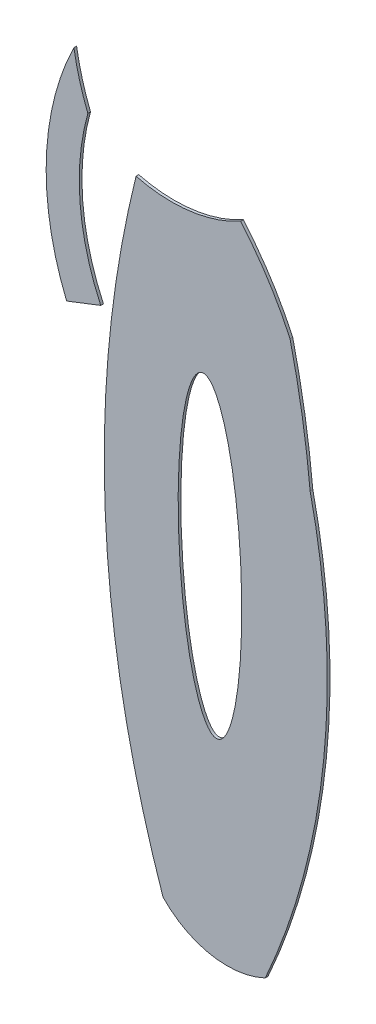
from build123d import *

# Parameters (mm, degrees)
SALIENTE_EXTRUIR1_DEPTH   = 0.1
MODEL_RX                  = 5.767455875
MODEL_RY                  = 1.157489638
SALIENTE_EXTRUIR1_2_DEPTH = 0.1


with BuildPart() as part:
    # Model → Saliente-Extruir1 (new body)
    with BuildSketch(Plane.XY):
        with BuildLine():
            Line((8.164460664, -25.912149457), (9.434463248, -25.418589136))
            ThreePointArc((9.434463248, -25.418589136), (8.663712085, -22.488322992), (8.954005148, -19.47232449))
            ThreePointArc((8.954005148, -19.47232449), (8.644531078, -18.555691694), (8.435601468, -17.611055097))
            ThreePointArc((8.435601468, -17.611055097), (7.409664196, -21.732519993), (8.164460664, -25.912149457))
        make_face()
    extrude(amount=SALIENTE_EXTRUIR1_DEPTH)


with BuildPart() as body_2:
    # Model → Saliente-Extruir1 2 (new body)
    with BuildSketch(Plane.XY):
        with BuildLine():
            ThreePointArc((15.55401823, -44.025149476), (17.728376415, -35.899156196), (17.222447112, -27.502511877))
            ThreePointArc((17.222447112, -27.502511877), (16.927732602, -25.223227177), (16.475194288, -22.969961888))
            ThreePointArc((16.475194288, -22.969961888), (15.655243323, -21.473904412), (14.635720073, -20.106030184))
            ThreePointArc((14.635720073, -20.106030184), (12.739052379, -20.722754687), (10.748454163, -20.59940075))
            ThreePointArc((10.748454163, -20.59940075), (9.603726479, -32.034356801), (11.752771541, -43.323742377))
            ThreePointArc((11.752771541, -43.323742377), (13.540053552, -44.288694584), (15.55401823, -44.025149476))
        make_face()
        with Locations(Location((13.497177395, -31.454583951), (0, 0, 92.484183825))):
            Ellipse(MODEL_RX, MODEL_RY, mode=Mode.SUBTRACT)
    extrude(amount=SALIENTE_EXTRUIR1_2_DEPTH)


solid = Compound([part.part, body_2.part])
